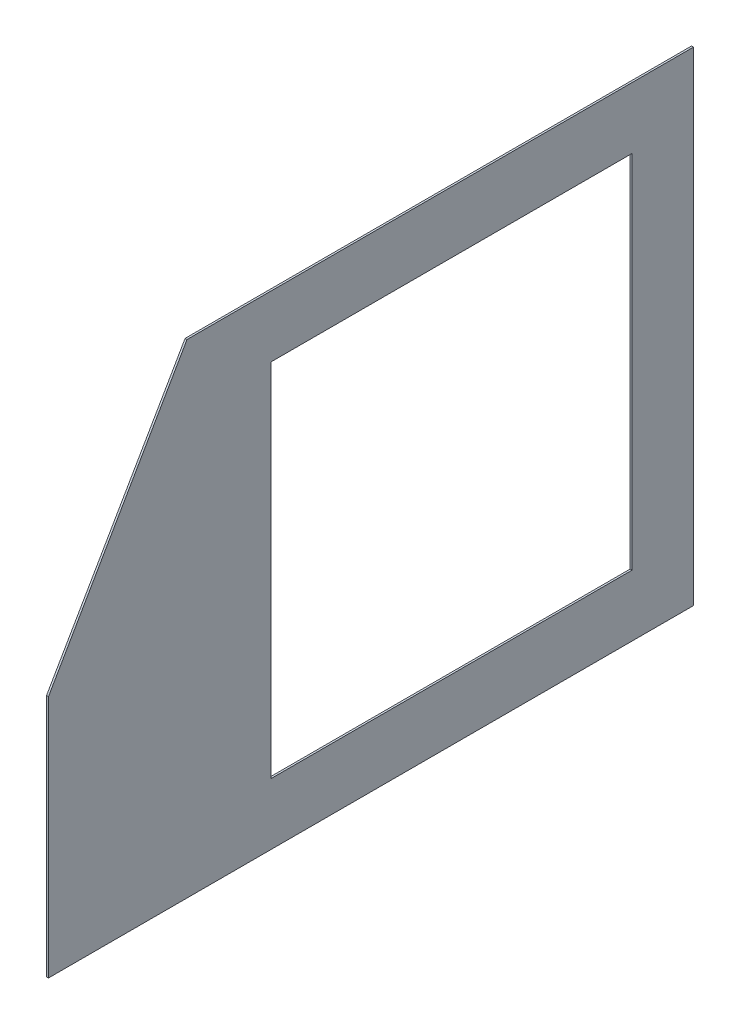
from build123d import *

# Parameters (mm, degrees)
BOSS_EXTRUDE1_DEPTH = 3.175
CUT_EXTRUDE1_REACH  = 5.175


with BuildPart() as part:
    # Sketch1 → Boss-Extrude1 (new body)
    with BuildSketch(Plane(origin=(0, 0, 0), x_dir=(0, 0, -1), z_dir=(1, 0, 0))):
        Polygon((0, 0), (-837.664111915, 0), (-1066.8, -396.875), (-1066.8, -800.1), (0, -800.1), align=None)
    extrude(amount=BOSS_EXTRUDE1_DEPTH)

    # Sketch2 → Cut-Extrude1 (cut, up to next)
    with BuildSketch(Plane(origin=(3.175, 0, 0), x_dir=(0, 0, -1), z_dir=(1, 0, 0)), mode=Mode.PRIVATE) as cut_extrude1_sk1:
        Polygon((-101.6, -396.875), (-101.6, -101.6), (-698.5, -101.6), (-698.5, -698.5), (-101.6, -698.5), align=None)
    cut_extrude1_tool1 = extrude(cut_extrude1_sk1.sketch, amount=-CUT_EXTRUDE1_REACH, mode=Mode.PRIVATE) & part.part
    add(cut_extrude1_tool1.solids().sort_by_distance((3.175, -400.05, 400.05))[0], mode=Mode.SUBTRACT)


solid = part.part
